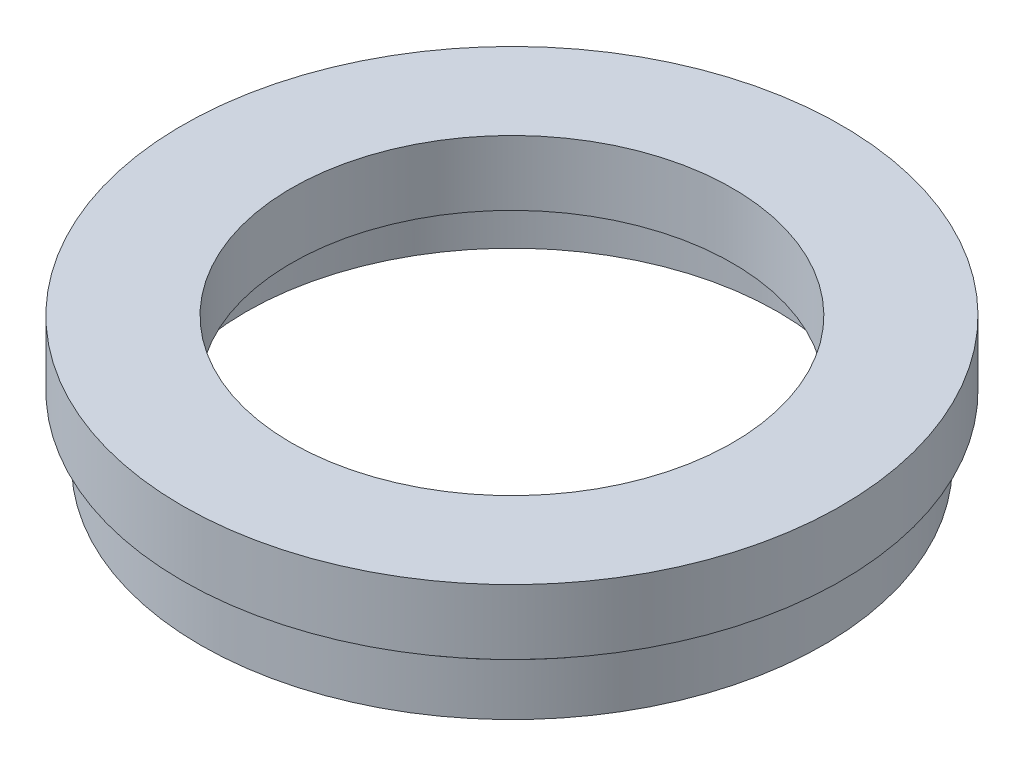
from build123d import *


with BuildPart() as part:
    # 草图1 → 旋转1 (revolve)
    with BuildSketch(Plane.XY, mode=Mode.PRIVATE) as revolve_1_sk:
        Polygon((20.5, 0), (20.5, 4), (21.1, 4), (21.1, 5), (17, 5), (17, 10), (25.4, 10), (25.4, 5), (23.5, 5), (23.5, 4), (24, 4), (24, 0), align=None)
    revolve(revolve_1_sk.sketch.rotate(Axis((0, 17.419298318, 0), (0, -1, 0)), 90), axis=Axis((0, 17.419298318, 0), (0, -1, 0)))  # turned: the seam where the file's is


solid = part.part
